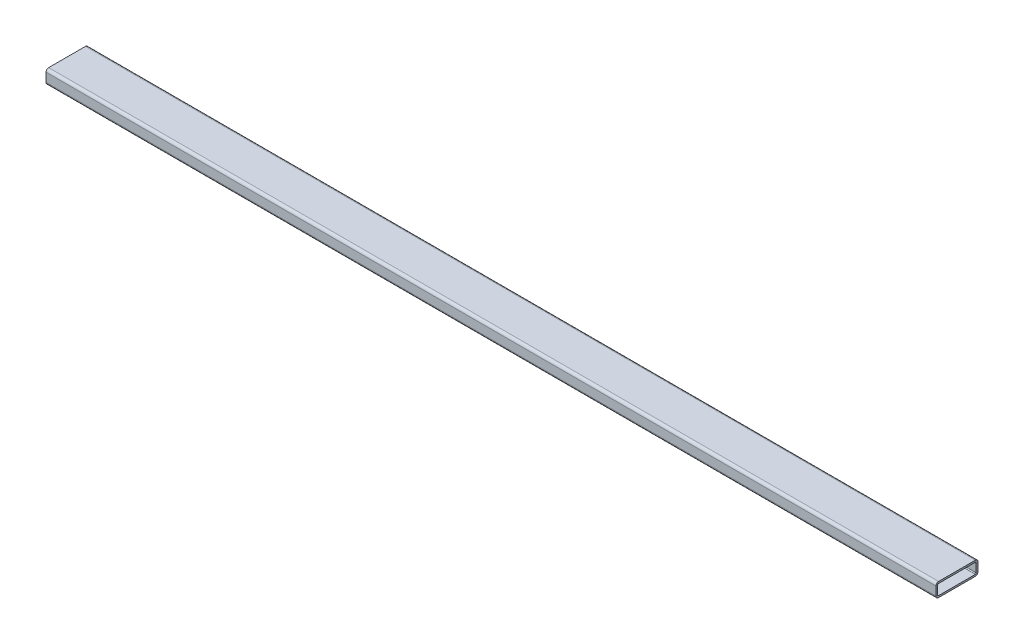
from build123d import *

# Parameters (mm, degrees)
BOSS_EXTRUDE1_DEPTH = 806.45


with BuildPart() as part:
    # Sketch1 → Boss-Extrude1 (new body, symmetric)
    with BuildSketch(Plane(origin=(0, 0, 0), x_dir=(0, 0, -1), z_dir=(1, 0, 0))):
        with BuildLine():
            Line((33.3248, 25.4), (-33.3248, 25.4))
            ThreePointArc((-33.3248, 25.4), (-36.701376302, 24.001376302), (-38.1, 20.6248))
            Line((-38.1, 20.6248), (-38.1, 4.7752))
            ThreePointArc((-38.1, 4.7752), (-36.701376302, 1.398623698), (-33.3248, 0))
            Line((-33.3248, 0), (33.3248, 0))
            ThreePointArc((33.3248, 0), (36.701376302, 1.398623698), (38.1, 4.7752))
            Line((38.1, 4.7752), (38.1, 20.6248))
            ThreePointArc((38.1, 20.6248), (36.701376302, 24.001376302), (33.3248, 25.4))
        make_face()
        with BuildLine():
            Line((33.3248, 22.225), (-33.3248, 22.225))
            ThreePointArc((-33.3248, 22.225), (-34.456312271, 21.756312271), (-34.925, 20.6248))
            Line((-34.925, 20.6248), (-34.925, 4.7752))
            ThreePointArc((-34.925, 4.7752), (-34.456312271, 3.643687729), (-33.3248, 3.175))
            Line((-33.3248, 3.175), (33.3248, 3.175))
            ThreePointArc((33.3248, 3.175), (34.456312271, 3.643687729), (34.925, 4.7752))
            Line((34.925, 4.7752), (34.925, 20.6248))
            ThreePointArc((34.925, 20.6248), (34.456312271, 21.756312271), (33.3248, 22.225))
        make_face(mode=Mode.SUBTRACT)
    extrude(amount=BOSS_EXTRUDE1_DEPTH, both=True)


solid = part.part
